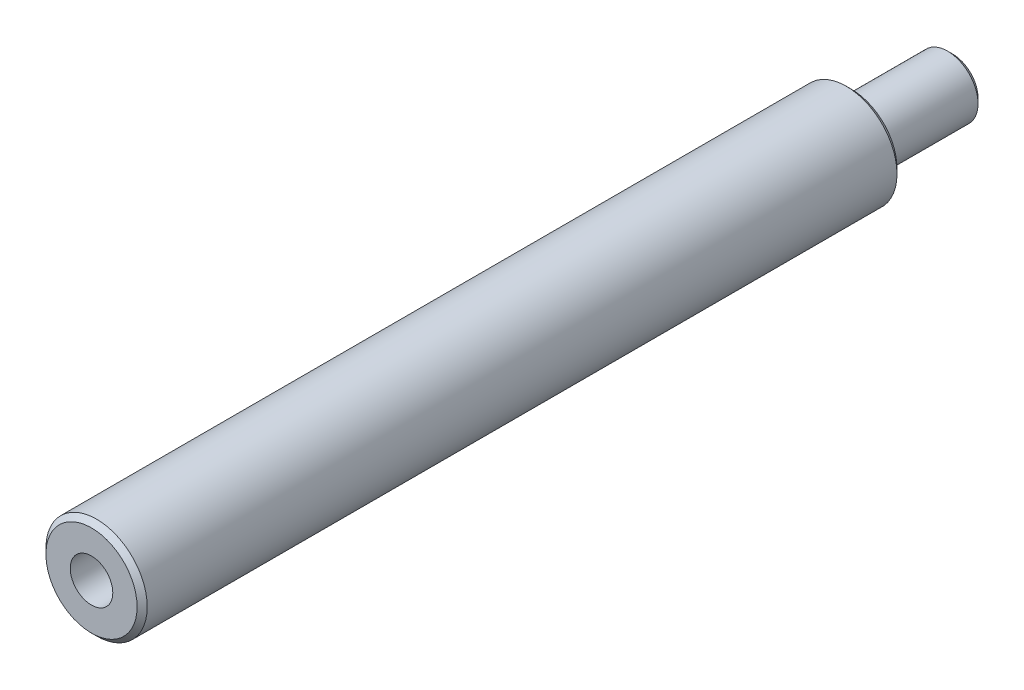
from build123d import *

# Parameters (mm, degrees)
ESQUISSE1_R                                   = 5
BOSS_EXTRU_1_DEPTH                            = 75
ESQUISSE2_R                                   = 3
BOSS_EXTRU_2_DEPTH                            = 10
TROU_POUR_TARAUDAGE_POUR_TROU_TARAUD_M5_D     = 4.2
TROU_POUR_TARAUDAGE_POUR_TROU_TARAUD_M5_DEPTH = 10
TROU_POUR_TARAUDAGE_POUR_TROU_TARAUD_M5_TIP   = 1.2618073
CHANFREIN1_SIZE                               = 0.5


with BuildPart() as part:
    # Esquisse1 → Boss.-Extru.1 (new body)
    with BuildSketch(Plane.XY):
        Circle(ESQUISSE1_R)
    extrude(amount=BOSS_EXTRU_1_DEPTH)

    # Esquisse2 → Boss.-Extru.2 (add)
    with BuildSketch(Plane(origin=(0, 0, 0), x_dir=(-1, 0, 0), z_dir=(0, 0, -1))):
        Circle(ESQUISSE2_R)
    extrude(amount=BOSS_EXTRU_2_DEPTH)

    # Trou pour taraudage pour trou taraudé M51
    with Locations(Plane.XY.offset(75)):
        with Locations((0, 0)):
            Hole(TROU_POUR_TARAUDAGE_POUR_TROU_TARAUD_M5_D / 2, depth=TROU_POUR_TARAUDAGE_POUR_TROU_TARAUD_M5_DEPTH)
            with Locations((0, 0, -(TROU_POUR_TARAUDAGE_POUR_TROU_TARAUD_M5_DEPTH + TROU_POUR_TARAUDAGE_POUR_TROU_TARAUD_M5_TIP / 2))):  # 118° drill point
                Cone(0, TROU_POUR_TARAUDAGE_POUR_TROU_TARAUD_M5_D / 2, TROU_POUR_TARAUDAGE_POUR_TROU_TARAUD_M5_TIP, mode=Mode.SUBTRACT)

    # Chanfrein1
    chanfrein1_edges = [part.edges().sort_by_distance(p)[0] for p in [
        (-5, 0, 0),
        (-5, 0, 75),
        (3, 0, -10),
    ]]
    chamfer(chanfrein1_edges, length=CHANFREIN1_SIZE)


solid = part.part
